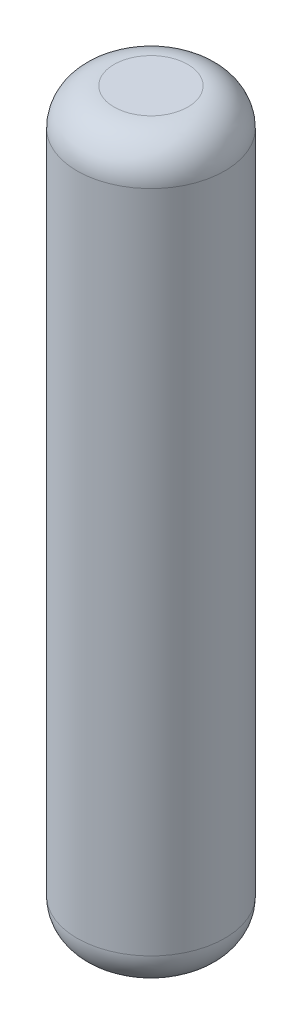
from build123d import *

# Parameters (mm, degrees)
CROQUIS1_R              = 2
SALIENTE_EXTRUIR1_DEPTH = 20
REDONDEO1_R             = 1


with BuildPart() as part:
    # Croquis1 → Saliente-Extruir1 (new body)
    with BuildSketch(Plane(origin=(0, 0, 0), x_dir=(1, 0, 0), z_dir=(0, 1, 0))):
        Circle(CROQUIS1_R)
    extrude(amount=SALIENTE_EXTRUIR1_DEPTH)

    # Redondeo1
    redondeo1_edges = [part.edges().sort_by_distance(p)[0] for p in [
        (-2, 0, 0),
        (-2, 20, 0),
    ]]
    fillet(redondeo1_edges, radius=REDONDEO1_R)


solid = part.part
